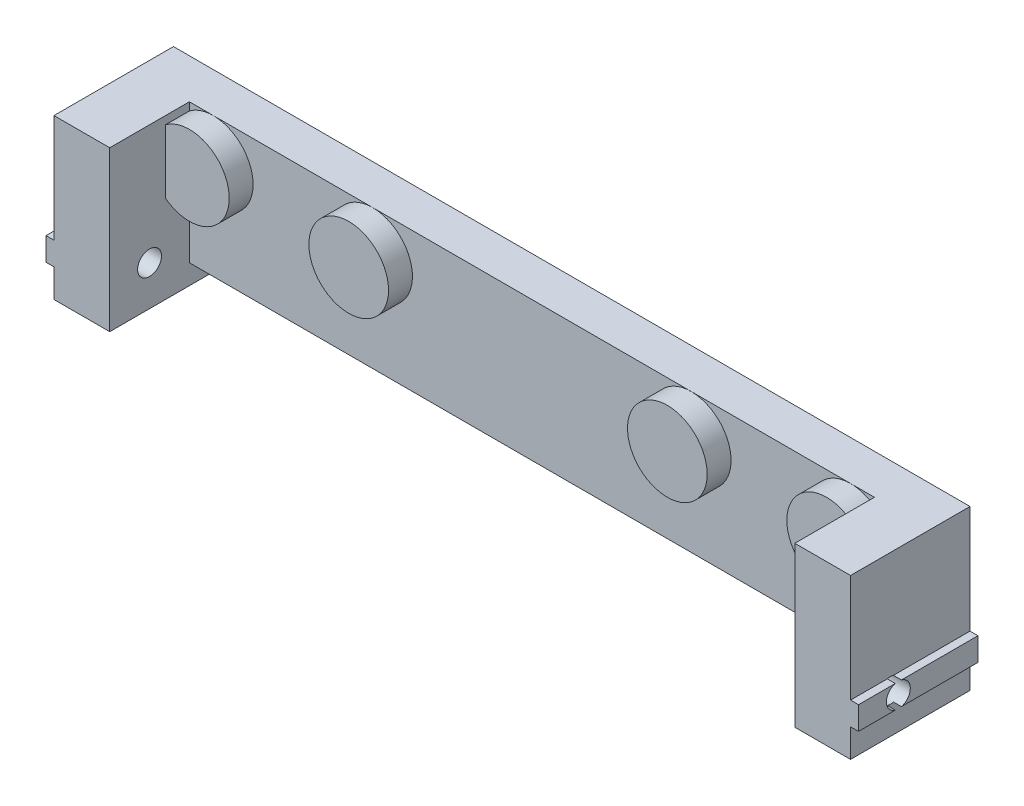
from build123d import *

# Parameters (mm, degrees)
MAIN_DEPTH               = 15
SKETCH2_W                = 86
SKETCH2_H                = 20
TOPEXTRUSION_DEPTH       = 10
SKETCH5_R                = 5
REINFORCEMENTHOLES_DEPTH = 3
SKETCH3_R                = 3
HOLES_DEPTH              = 5
SKETCH4_R                = 1.5
FIXHOLES_DEPTH           = 103
SKETCH6_W                = 86
SKETCH6_H                = 2.5
FORWINDOW_DEPTH          = 6
SKETCH7_R                = 1.25
CUT_EXTRUDE2_DEPTH       = 10


with BuildPart() as part:
    # Sketch1 → Main (new body)
    with BuildSketch(Plane.XY):
        Polygon((-50, 0), (50, 0), (50, 3.55), (51, 3.55), (51, 6.45), (50, 6.45), (50, 20), (-50, 20), (-50, 6.45), (-51, 6.45), (-51, 3.55), (-50, 3.55), align=None)
    extrude(amount=MAIN_DEPTH)

    # Sketch2 → TopExtrusion (cut)
    with BuildSketch(Plane.XY.offset(15)):
        with Locations((0, 10)):
            Rectangle(SKETCH2_W, SKETCH2_H)
    extrude(amount=-TOPEXTRUSION_DEPTH, mode=Mode.SUBTRACT)

    # Sketch5 → ReinforcementHoles (add)
    with BuildSketch(Plane.XY.offset(5)):
        with Locations((-40, 15)):
            Circle(SKETCH5_R)
        with Locations((-20, 15)):
            Circle(SKETCH5_R)
        with Locations((20, 15)):
            Circle(SKETCH5_R)
        with Locations((40, 15)):
            Circle(SKETCH5_R)
    extrude(amount=REINFORCEMENTHOLES_DEPTH)

    # Sketch3 → Holes (cut)
    with BuildSketch(Plane.XY):
        with Locations((-40, 15)):
            Circle(SKETCH3_R)
        with Locations((20, 15)):
            Circle(SKETCH3_R)
    holes = extrude(amount=HOLES_DEPTH, mode=Mode.SUBTRACT)

    # Mirror1: Holes across plane
    add(holes.mirror(Plane(origin=(0, 0, 0), x_dir=(0, 0, 1), z_dir=(1, 0, 0))), mode=Mode.SUBTRACT)

    # Sketch4 → FixHoles (cut, through all)
    with BuildSketch(Plane(origin=(51, 0, 0), x_dir=(0, 0, -1), z_dir=(1, 0, 0))):
        with Locations((-10, 5)):
            Circle(SKETCH4_R)
    extrude(amount=-FIXHOLES_DEPTH, mode=Mode.SUBTRACT)

    # Sketch6 → ForWindow (cut, through all)
    with BuildSketch(Plane.XY.offset(5)):
        with Locations((0, 1.25)):
            Rectangle(SKETCH6_W, SKETCH6_H)
    extrude(amount=-FORWINDOW_DEPTH, mode=Mode.SUBTRACT)

    # Sketch7 → Cut-Extrude2 (cut)
    with BuildSketch(Plane(origin=(0, 2.5, 0), x_dir=(-1, 0, 0), z_dir=(0, -1, 0))):
        with Locations((36, -2.5)):
            Circle(SKETCH7_R)
        with Locations((-36, -2.5)):
            Circle(SKETCH7_R)
    extrude(amount=-CUT_EXTRUDE2_DEPTH, mode=Mode.SUBTRACT)


solid = part.part
